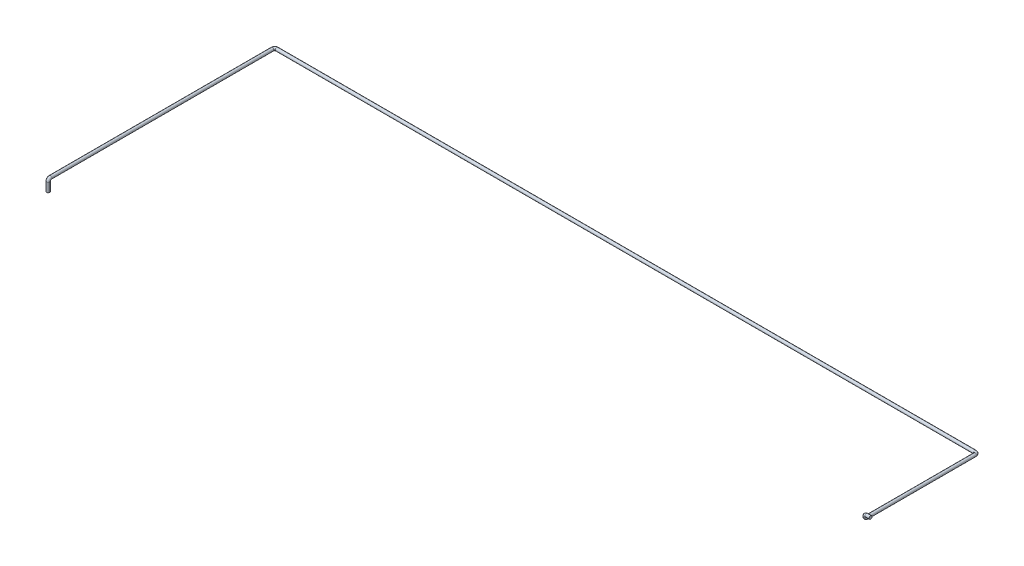
from build123d import *

# Parameters (mm, degrees)
CROQUIS1_R = 13.7


with BuildPart() as part:
    # Barrer1: sweep along a curve in space
    with BuildLine() as barrer1_path:
        Line((0, 0, 0), (-36, 0, 0))
        ThreePointArc((-36, 0, 0), (-45.899494937, -4.100505063, 0), (-50, -14, 0))
        Line((-50, -14, 0), (-50, -16, 0))
        ThreePointArc((-50, -16, 0), (-50, -25.899494937, -4.100505063), (-50, -30, -14))
        Line((-50, -30, -14), (-50, -30, -980))
        ThreePointArc((-50, -30, -980), (-55.857864376, -30, -994.142135624), (-70, -30, -1000))
        Line((-70, -30, -1000), (-6295, -30, -1000))
        ThreePointArc((-6295, -30, -1000), (-6309.142135624, -30, -994.142135624), (-6315, -30, -980))
        Line((-6315, -30, -980), (-6315, -30, 1000))
        ThreePointArc((-6315, -30, 1000), (-6315, -35.857864376, 1014.142135624), (-6315, -50, 1020))
        Line((-6315, -50, 1020), (-6315, -130, 1020))
    # Croquis1 → Barrer1 (sweep)
    with BuildSketch(Plane(origin=(0, 0, 0), x_dir=(0, 0, -1), z_dir=(1, 0, 0))):
        Circle(CROQUIS1_R)
    sweep(path=barrer1_path.line)


solid = part.part
